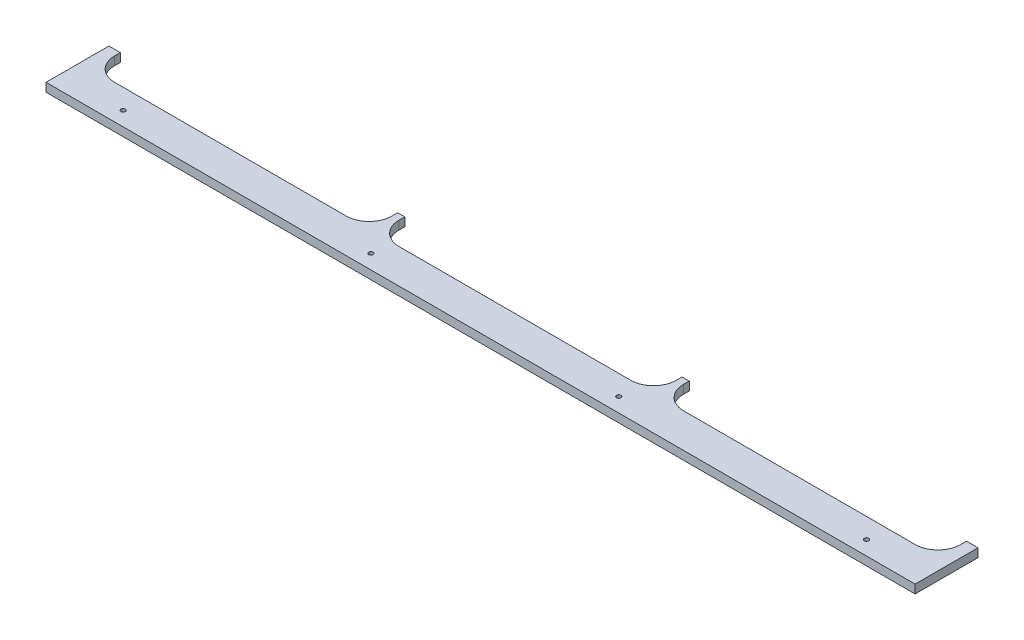
from build123d import *

# Parameters (mm, degrees)
SKETCH1_R           = 2.45745
BOSS_EXTRUDE1_DEPTH = 9.525


with BuildPart() as part:
    # Sketch1 → Boss-Extrude1 (new body)
    with BuildSketch(Plane(origin=(0, 0, 0), x_dir=(1, 0, 0), z_dir=(0, 1, 0))):
        with BuildLine():
            Line((0, 0), (965.2, 0))
            Line((965.2, 0), (965.2, 69.85))
            Line((965.2, 69.85), (952.5, 69.85))
            Line((952.5, 69.85), (952.5, 63.5))
            ThreePointArc((952.5, 63.5), (945.060512242, 45.539487758), (927.1, 38.1))
            Line((927.1, 38.1), (669.925, 38.1))
            ThreePointArc((669.925, 38.1), (651.964487758, 45.539487758), (644.525, 63.5))
            Line((644.525, 63.5), (644.525, 69.85))
            Line((644.525, 69.85), (636.5875, 69.85))
            Line((636.5875, 69.85), (636.5875, 63.5))
            ThreePointArc((636.5875, 63.5), (629.148012242, 45.539487758), (611.1875, 38.1))
            Line((611.1875, 38.1), (354.0125, 38.1))
            ThreePointArc((354.0125, 38.1), (336.051987758, 45.539487758), (328.6125, 63.5))
            Line((328.6125, 63.5), (328.6125, 69.85))
            Line((328.6125, 69.85), (320.675, 69.85))
            Line((320.675, 69.85), (320.675, 63.5))
            ThreePointArc((320.675, 63.5), (313.235512242, 45.539487758), (295.275, 38.1))
            Line((295.275, 38.1), (38.1, 38.1))
            ThreePointArc((38.1, 38.1), (20.139487758, 45.539487758), (12.7, 63.5))
            Line((12.7, 63.5), (12.7, 69.85))
            Line((12.7, 69.85), (0, 69.85))
            Line((0, 69.85), (0, 0))
        make_face()
        with Locations((69.85, 15.875)):
            Circle(SKETCH1_R, mode=Mode.SUBTRACT)
        with Locations((345.01582, 15.875)):
            Circle(SKETCH1_R, mode=Mode.SUBTRACT)
        with Locations((895.35, 15.875)):
            Circle(SKETCH1_R, mode=Mode.SUBTRACT)
        with Locations((620.18418, 15.875)):
            Circle(SKETCH1_R, mode=Mode.SUBTRACT)
    extrude(amount=BOSS_EXTRUDE1_DEPTH)


solid = part.part
